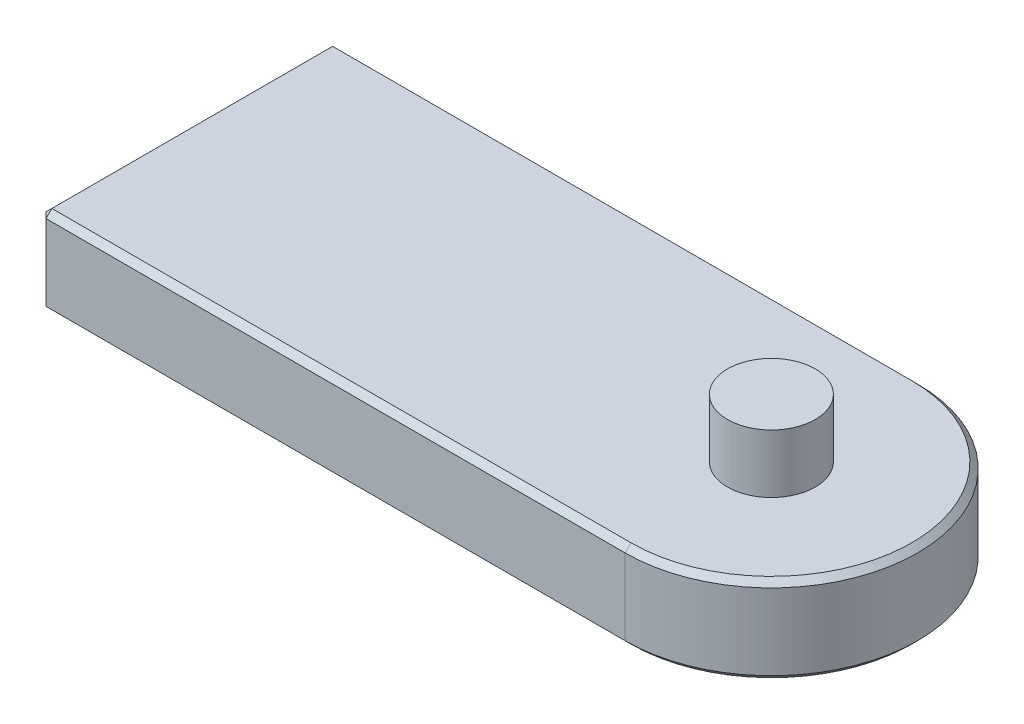
from build123d import *

# Parameters (mm, degrees)
BOSS_EXTRUDE1_DEPTH = 30
SKETCH2_R           = 15
BOSS_EXTRUDE2_DEPTH = 20
CHAMFER1_SIZE       = 2


with BuildPart() as part:
    # Sketch1 → Boss-Extrude1 (new body)
    with BuildSketch(Plane(origin=(0, 0, 0), x_dir=(1, 0, 0), z_dir=(0, 1, 0))):
        with BuildLine():
            Line((100, 50), (-100, 50))
            Line((-100, 50), (-100, -50))
            Line((-100, -50), (100, -50))
            ThreePointArc((100, -50), (150, 0), (100, 50))
        make_face()
    extrude(amount=BOSS_EXTRUDE1_DEPTH)

    # Sketch2 → Boss-Extrude2 (add)
    with BuildSketch(Plane(origin=(0, 30, 0), x_dir=(1, 0, 0), z_dir=(0, 1, 0))):
        with Locations((100, 0)):
            Circle(SKETCH2_R)
    extrude(amount=BOSS_EXTRUDE2_DEPTH)

    # Chamfer1
    chamfer1_edges = [part.edges().sort_by_distance(p)[0] for p in [
        (-100, 30, 0),
        (0, 30, 50),
        (150, 30, 0),
        (0, 0, 50),
        (-100, 0, 0),
        (0, 0, -50),
        (150, 0, 0),
        (-100, 15, 50),
        (-100, 15, -50),
        (0, 30, -50),
    ]]
    chamfer(chamfer1_edges, length=CHAMFER1_SIZE)


solid = part.part
